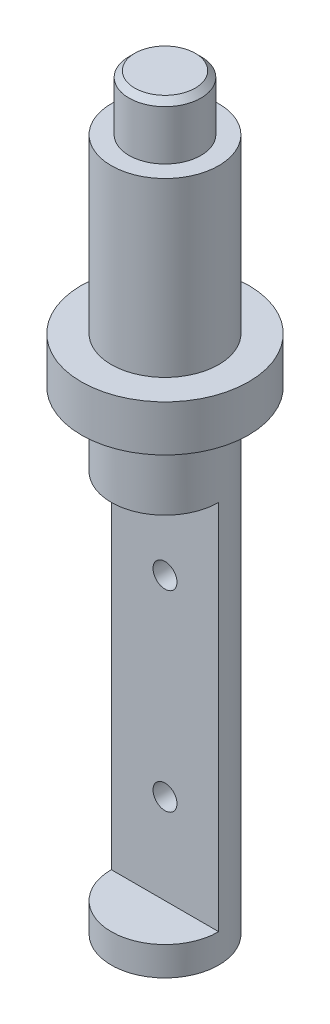
from build123d import *

# Parameters (mm, degrees)
SKETCH1_R           = 28
BOSS_EXTRUDE1_DEPTH = 118.7
SKETCH3_R           = 43.6
BOSS_EXTRUDE2_DEPTH = 24
SKETCH4_R           = 28
SKETCH4_R_2         = 18.75
CUT_EXTRUDE1_DEPTH  = 28.9
CHAMFER1_SIZE       = 3
SKETCH6_R           = 28
BOSS_EXTRUDE3_DEPTH = 38.2
BOSS_EXTRUDE4_DEPTH = 193.8
SKETCH9_R           = 28
BOSS_EXTRUDE5_DEPTH = 15.1
SKETCH10_R          = 6.25
CUT_EXTRUDE2_DEPTH  = 28.1


with BuildPart() as part:
    # Sketch1 → Boss-Extrude1 (new body)
    with BuildSketch(Plane(origin=(0, 0, 0), x_dir=(1, 0, 0), z_dir=(0, 1, 0))):
        Circle(SKETCH1_R)
    extrude(amount=-BOSS_EXTRUDE1_DEPTH)

    # Sketch3 → Boss-Extrude2 (add)
    with BuildSketch(Plane.XZ.offset(118.7)):
        Circle(SKETCH3_R)
    extrude(amount=BOSS_EXTRUDE2_DEPTH)

    # Sketch4 → Cut-Extrude1 (cut)
    with BuildSketch(Plane(origin=(0, 0, 0), x_dir=(1, 0, 0), z_dir=(0, 1, 0))):
        Circle(SKETCH4_R)
        Circle(SKETCH4_R_2, mode=Mode.SUBTRACT)
    extrude(amount=-CUT_EXTRUDE1_DEPTH, mode=Mode.SUBTRACT)

    # Chamfer1
    chamfer1_edges = [part.edges().sort_by_distance(p)[0] for p in [
        (-18.75, 0, 0),
    ]]
    chamfer(chamfer1_edges, length=CHAMFER1_SIZE)

    # Sketch6 → Boss-Extrude3 (add)
    with BuildSketch(Plane.XZ.offset(142.7)):
        Circle(SKETCH6_R)
    extrude(amount=BOSS_EXTRUDE3_DEPTH)

    # Sketch8 → Boss-Extrude4 (add)
    with BuildSketch(Plane.XZ.offset(180.9)):
        with BuildLine():
            Line((-28, 0), (28, 0))
            ThreePointArc((28, 0), (0, -28), (-28, 0))
        make_face()
    extrude(amount=BOSS_EXTRUDE4_DEPTH)

    # Sketch9 → Boss-Extrude5 (add)
    with BuildSketch(Plane.XZ.offset(374.7)):
        Circle(SKETCH9_R)
    extrude(amount=BOSS_EXTRUDE5_DEPTH)

    # Sketch10 → Cut-Extrude2 (cut)
    with BuildSketch(Plane.XY):
        with Locations((0, -227.8)):
            Circle(SKETCH10_R)
        with Locations((0, -327.8)):
            Circle(SKETCH10_R)
    extrude(amount=-CUT_EXTRUDE2_DEPTH, mode=Mode.SUBTRACT)


solid = part.part
